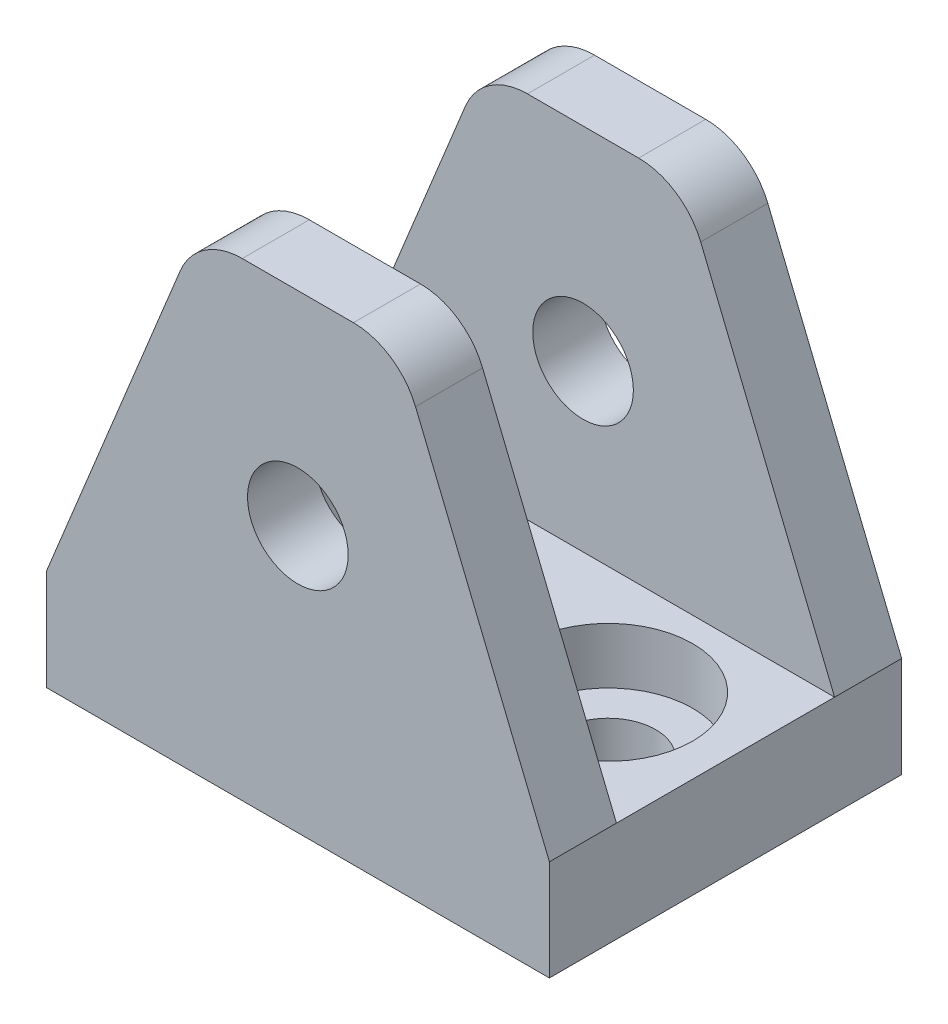
from build123d import *

# Parameters (mm, degrees)
SKETCH1_W                               = 47.625
SKETCH1_H                               = 33.3502
BOSS_EXTRUDE1_DEPTH                     = 44.45
SKETCH2_W                               = 47.625
SKETCH2_H                               = 20.6502
CUT_EXTRUDE1_DEPTH                      = 34.925
CUT_EXTRUDE2_DEPTH                      = 1
CUT_EXTRUDE2_DEPTH_BACK                 = 34.3502
CBORE_FOR_M8_HEX_HEAD_BOLT1_D           = 9
CBORE_FOR_M8_HEX_HEAD_BOLT1_DEPTH       = 13.298127214
CBORE_FOR_M8_HEX_HEAD_BOLT1_CBORE_D     = 16
CBORE_FOR_M8_HEX_HEAD_BOLT1_CBORE_DEPTH = 5.3
CBORE_FOR_M8_HEX_HEAD_BOLT1_TIP         = 2.703872786
FILLET3_R                               = 6.35
F_3_8_0_375_DIAMETER_HOLE1_D            = 9.525


with BuildPart() as part:
    # Sketch1 → Boss-Extrude1 (new body)
    with BuildSketch(Plane(origin=(0, 0, 0), x_dir=(1, 0, 0), z_dir=(0, 1, 0))):
        Rectangle(SKETCH1_W, SKETCH1_H)
    extrude(amount=BOSS_EXTRUDE1_DEPTH)

    # Sketch2 → Cut-Extrude1 (cut)
    with BuildSketch(Plane(origin=(0, 44.45, 0), x_dir=(1, 0, 0), z_dir=(0, 1, 0))):
        Rectangle(SKETCH2_W, SKETCH2_H)
    extrude(amount=-CUT_EXTRUDE1_DEPTH, mode=Mode.SUBTRACT)

    # Sketch3 → Cut-Extrude2 (cut, two sides)
    with BuildSketch(Plane(origin=(0, 0, -16.6751), x_dir=(-1, 0, 0), z_dir=(0, 0, -1))) as cut_extrude2_sk:
        Polygon((23.8125, 44.45), (9.525, 44.45), (23.8125, 9.525), align=None)
        Polygon((-23.8125, 9.525), (-9.525, 44.45), (-23.8125, 44.45), align=None)
    extrude(amount=CUT_EXTRUDE2_DEPTH, mode=Mode.SUBTRACT)
    extrude(cut_extrude2_sk.sketch, amount=-CUT_EXTRUDE2_DEPTH_BACK, mode=Mode.SUBTRACT)

    # CBORE for M8 Hex Head Bolt1
    with Locations(Plane(origin=(0, 9.525, 0), x_dir=(1, 0, 0), z_dir=(0, 1, 0))):
        with Locations((-12.7, 0), (12.7, 0)):
            CounterBoreHole(CBORE_FOR_M8_HEX_HEAD_BOLT1_D / 2, CBORE_FOR_M8_HEX_HEAD_BOLT1_CBORE_D / 2, CBORE_FOR_M8_HEX_HEAD_BOLT1_CBORE_DEPTH, depth=CBORE_FOR_M8_HEX_HEAD_BOLT1_DEPTH)
            with Locations((0, 0, -(CBORE_FOR_M8_HEX_HEAD_BOLT1_DEPTH + CBORE_FOR_M8_HEX_HEAD_BOLT1_TIP / 2))):  # 118° drill point
                Cone(0, CBORE_FOR_M8_HEX_HEAD_BOLT1_D / 2, CBORE_FOR_M8_HEX_HEAD_BOLT1_TIP, mode=Mode.SUBTRACT)

    # Fillet3
    fillet3_edges = [part.edges().sort_by_distance(p)[0] for p in [
        (9.525, 44.45, 13.5001),
        (-9.525, 44.45, 13.5001),
        (9.525, 44.45, -13.5001),
        (-9.525, 44.45, -13.5001),
    ]]
    fillet(fillet3_edges, radius=FILLET3_R)

    # 3/8 (0.375) Diameter Hole1 (through all)
    with Locations(Plane.XY.offset(16.6751)):
        with Locations((0, 25.161662577)):
            Hole(F_3_8_0_375_DIAMETER_HOLE1_D / 2)


solid = part.part
